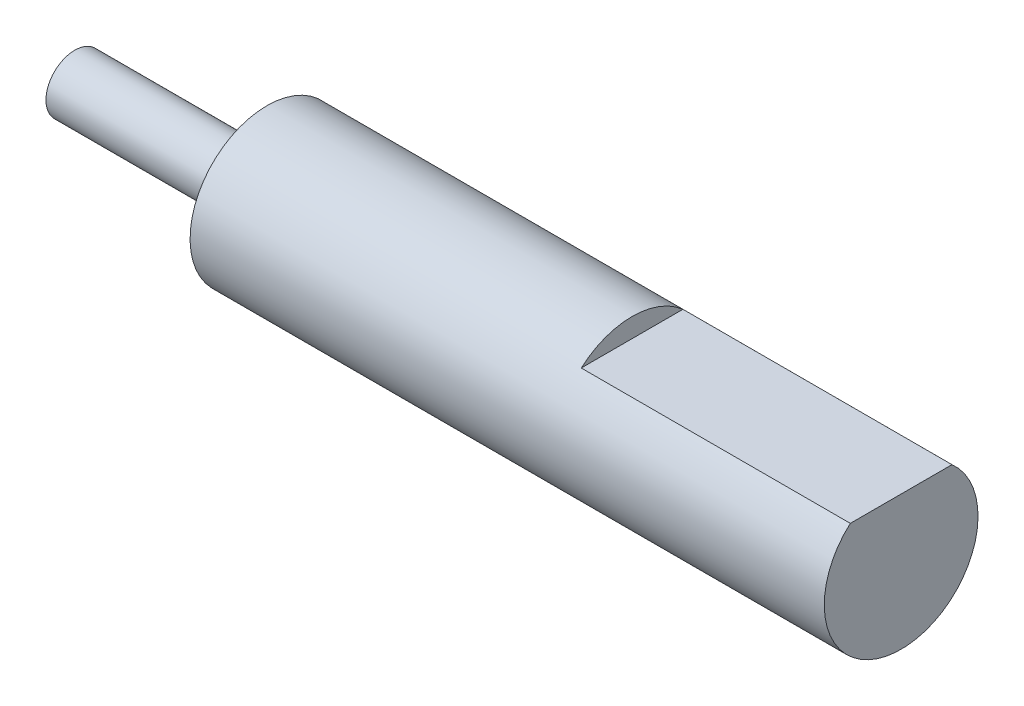
from build123d import *

# Parameters (mm, degrees)
SKETCH1_R           = 1.5
BOSS_EXTRUDE1_DEPTH = 10
BOSS_EXTRUDE2_DEPTH = 33
BOSS_EXTRUDE3_DEPTH = 19


with BuildPart() as part:
    # Sketch1 → Boss-Extrude1 (new body)
    with BuildSketch(Plane(origin=(0, 0, 0), x_dir=(0, 0, -1), z_dir=(1, 0, 0))):
        Circle(SKETCH1_R)
    extrude(amount=-BOSS_EXTRUDE1_DEPTH)

    # Sketch1_3 → Boss-Extrude2 (add)
    with BuildSketch(Plane(origin=(0, 0, 0), x_dir=(0, 0, -1), z_dir=(1, 0, 0))):
        with BuildLine():
            Line((2.645751311, 3), (-2.645751311, 3))
            ThreePointArc((-2.645751311, 3), (0, -4), (2.645751311, 3))
        make_face()
    extrude(amount=BOSS_EXTRUDE2_DEPTH)

    # Sketch1_4 → Boss-Extrude3 (add)
    with BuildSketch(Plane(origin=(0, 0, 0), x_dir=(0, 0, -1), z_dir=(1, 0, 0))):
        with BuildLine():
            Line((-2.645751311, 3), (2.645751311, 3))
            ThreePointArc((2.645751311, 3), (0, 4), (-2.645751311, 3))
        make_face()
    extrude(amount=BOSS_EXTRUDE3_DEPTH)


solid = part.part
